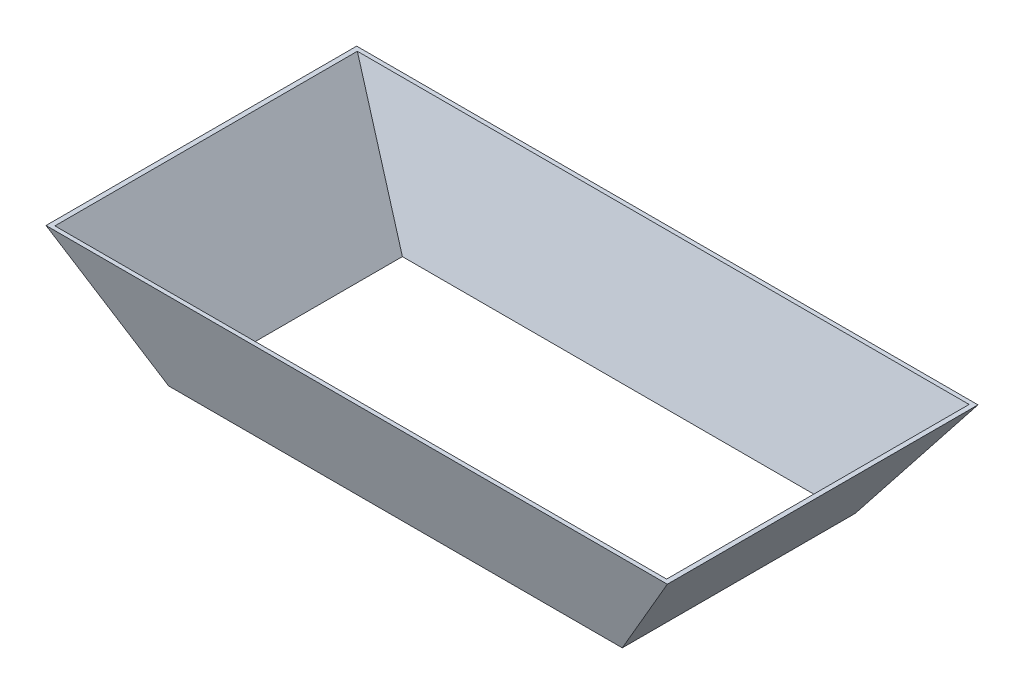
from build123d import *

# Parameters (mm, degrees)
SKETCH2_W = 800
SKETCH2_H = 400
SKETCH1_W = 584
SKETCH1_H = 300
SHELL1_T  = -5


with BuildPart() as part:
    # Sketch2 → Loft1 section 0
    with BuildSketch(Plane(origin=(0, 150, 0), x_dir=(1, 0, 0), z_dir=(0, 1, 0))):
        Rectangle(SKETCH2_W, SKETCH2_H)
    # Sketch1 → Loft1 section 1
    with BuildSketch(Plane(origin=(0, 0, 0), x_dir=(1, 0, 0), z_dir=(0, 1, 0))):
        Rectangle(SKETCH1_W, SKETCH1_H)
    loft()

    # Shell1
    shell1_openings = [part.faces().sort_by_distance(p)[0] for p in [
        (0, 0, 0),
        (0, 150, 0),
    ]]
    offset(amount=SHELL1_T, openings=shell1_openings, kind=Kind.INTERSECTION)


solid = part.part
